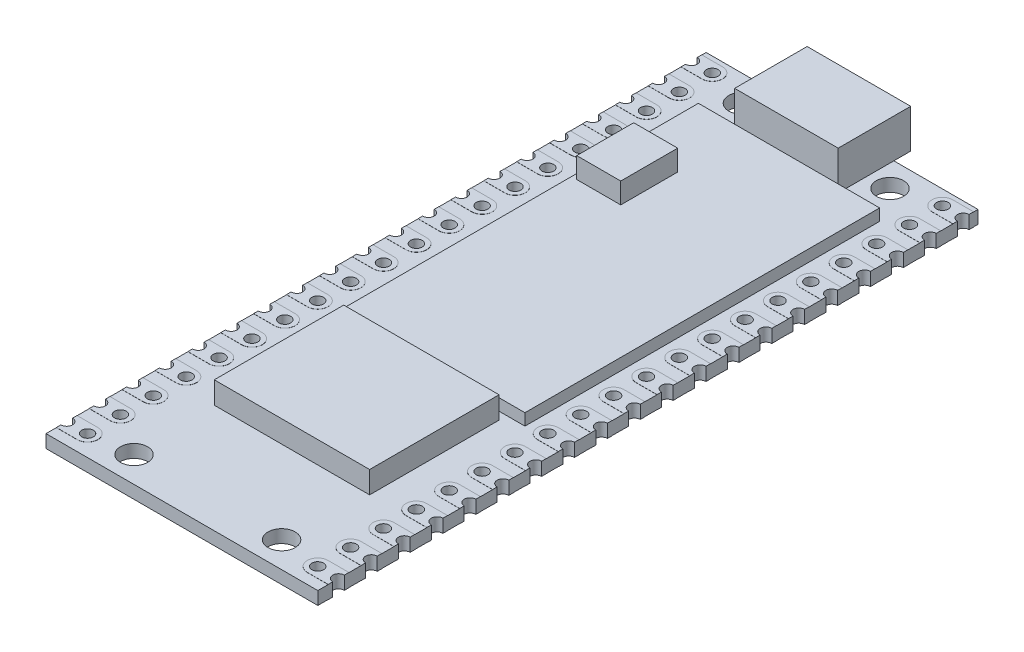
from build123d import *

# Parameters (mm, degrees)
SKETCH1_R                = 1.05
SKETCH1_R_2              = 0.45
BOSS_EXTRUDE1_DEPTH      = 1
SKETCH2_W                = 8
SKETCH2_H                = 5.6
BOSS_EXTRUDE2_DEPTH      = 3
SKETCH3_R                = 0.45
BOSS_EXTRUDE3_DEPTH      = 0.01
BOSS_EXTRUDE3_DEPTH_BACK = 1.01
SKETCH4_W                = 14
SKETCH4_H                = 27.4
BOSS_EXTRUDE4_DEPTH      = 0.9
SKETCH5_W                = 3.4
SKETCH5_H                = 4.4
BOSS_EXTRUDE5_DEPTH      = 2.5
SKETCH6_W                = 12
SKETCH6_H                = 10
BOSS_EXTRUDE6_DEPTH      = 1.7


with BuildPart() as part:
    # Sketch1 → Boss-Extrude1 (new body)
    with BuildSketch(Plane(origin=(0, 0, 0), x_dir=(1, 0, 0), z_dir=(0, 1, 0))):
        with BuildLine():
            Line((-10.5, 0), (10.5, 0))
            Line((10.5, 0), (10.5, -0.69))
            ThreePointArc((10.5, -0.69), (10.05, -1.14), (10.5, -1.59))
            Line((10.5, -1.59), (10.5, -3.23))
            ThreePointArc((10.5, -3.23), (10.05, -3.68), (10.5, -4.13))
            Line((10.5, -4.13), (10.5, -5.77))
            ThreePointArc((10.5, -5.77), (10.05, -6.22), (10.5, -6.67))
            Line((10.5, -6.67), (10.5, -8.31))
            ThreePointArc((10.5, -8.31), (10.05, -8.76), (10.5, -9.21))
            Line((10.5, -9.21), (10.5, -10.85))
            ThreePointArc((10.5, -10.85), (10.05, -11.3), (10.5, -11.75))
            Line((10.5, -11.75), (10.5, -13.39))
            ThreePointArc((10.5, -13.39), (10.05, -13.84), (10.5, -14.29))
            Line((10.5, -14.29), (10.5, -15.93))
            ThreePointArc((10.5, -15.93), (10.05, -16.38), (10.5, -16.83))
            Line((10.5, -16.83), (10.5, -18.47))
            ThreePointArc((10.5, -18.47), (10.05, -18.92), (10.5, -19.37))
            Line((10.5, -19.37), (10.5, -21.01))
            ThreePointArc((10.5, -21.01), (10.05, -21.46), (10.5, -21.91))
            Line((10.5, -21.91), (10.5, -23.55))
            ThreePointArc((10.5, -23.55), (10.05, -24), (10.5, -24.45))
            Line((10.5, -24.45), (10.5, -26.09))
            ThreePointArc((10.5, -26.09), (10.05, -26.54), (10.5, -26.99))
            Line((10.5, -26.99), (10.5, -28.63))
            ThreePointArc((10.5, -28.63), (10.05, -29.08), (10.5, -29.53))
            Line((10.5, -29.53), (10.5, -31.17))
            ThreePointArc((10.5, -31.17), (10.05, -31.62), (10.5, -32.07))
            Line((10.5, -32.07), (10.5, -33.71))
            ThreePointArc((10.5, -33.71), (10.05, -34.16), (10.5, -34.61))
            Line((10.5, -34.61), (10.5, -36.25))
            ThreePointArc((10.5, -36.25), (10.05, -36.7), (10.5, -37.15))
            Line((10.5, -37.15), (10.5, -38.79))
            ThreePointArc((10.5, -38.79), (10.05, -39.24), (10.5, -39.69))
            Line((10.5, -39.69), (10.5, -41.33))
            ThreePointArc((10.5, -41.33), (10.05, -41.78), (10.5, -42.23))
            Line((10.5, -42.23), (10.5, -43.87))
            ThreePointArc((10.5, -43.87), (10.05, -44.32), (10.5, -44.77))
            Line((10.5, -44.77), (10.5, -46.41))
            ThreePointArc((10.5, -46.41), (10.05, -46.86), (10.5, -47.31))
            Line((10.5, -47.31), (10.5, -48.95))
            ThreePointArc((10.5, -48.95), (10.05, -49.4), (10.5, -49.85))
            Line((10.5, -49.85), (10.5, -51))
            Line((10.5, -51), (-10.5, -51))
            Line((-10.5, -51), (-10.5, -49.85))
            ThreePointArc((-10.5, -49.85), (-10.05, -49.4), (-10.5, -48.95))
            Line((-10.5, -48.95), (-10.5, -47.31))
            ThreePointArc((-10.5, -47.31), (-10.05, -46.86), (-10.5, -46.41))
            Line((-10.5, -46.41), (-10.5, -44.77))
            ThreePointArc((-10.5, -44.77), (-10.05, -44.32), (-10.5, -43.87))
            Line((-10.5, -43.87), (-10.5, -42.23))
            ThreePointArc((-10.5, -42.23), (-10.05, -41.78), (-10.5, -41.33))
            Line((-10.5, -41.33), (-10.5, -39.69))
            ThreePointArc((-10.5, -39.69), (-10.05, -39.24), (-10.5, -38.79))
            Line((-10.5, -38.79), (-10.5, -37.15))
            ThreePointArc((-10.5, -37.15), (-10.05, -36.7), (-10.5, -36.25))
            Line((-10.5, -36.25), (-10.5, -34.61))
            ThreePointArc((-10.5, -34.61), (-10.05, -34.16), (-10.5, -33.71))
            Line((-10.5, -33.71), (-10.5, -32.07))
            ThreePointArc((-10.5, -32.07), (-10.05, -31.62), (-10.5, -31.17))
            Line((-10.5, -31.17), (-10.5, -29.53))
            ThreePointArc((-10.5, -29.53), (-10.05, -29.08), (-10.5, -28.63))
            Line((-10.5, -28.63), (-10.5, -26.99))
            ThreePointArc((-10.5, -26.99), (-10.05, -26.54), (-10.5, -26.09))
            Line((-10.5, -26.09), (-10.5, -24.45))
            ThreePointArc((-10.5, -24.45), (-10.05, -24), (-10.5, -23.55))
            Line((-10.5, -23.55), (-10.5, -21.91))
            ThreePointArc((-10.5, -21.91), (-10.05, -21.46), (-10.5, -21.01))
            Line((-10.5, -21.01), (-10.5, -19.37))
            ThreePointArc((-10.5, -19.37), (-10.05, -18.92), (-10.5, -18.47))
            Line((-10.5, -18.47), (-10.5, -16.83))
            ThreePointArc((-10.5, -16.83), (-10.05, -16.38), (-10.5, -15.93))
            Line((-10.5, -15.93), (-10.5, -14.29))
            ThreePointArc((-10.5, -14.29), (-10.05, -13.84), (-10.5, -13.39))
            Line((-10.5, -13.39), (-10.5, -11.75))
            ThreePointArc((-10.5, -11.75), (-10.05, -11.3), (-10.5, -10.85))
            Line((-10.5, -10.85), (-10.5, -9.21))
            ThreePointArc((-10.5, -9.21), (-10.05, -8.76), (-10.5, -8.31))
            Line((-10.5, -8.31), (-10.5, -6.67))
            ThreePointArc((-10.5, -6.67), (-10.05, -6.22), (-10.5, -5.77))
            Line((-10.5, -5.77), (-10.5, -4.13))
            ThreePointArc((-10.5, -4.13), (-10.05, -3.68), (-10.5, -3.23))
            Line((-10.5, -3.23), (-10.5, -1.59))
            ThreePointArc((-10.5, -1.59), (-10.05, -1.14), (-10.5, -0.69))
            Line((-10.5, -0.69), (-10.5, 0))
        make_face()
        with Locations(Location((-5.7, -2, 0), (0, 0, 270))):
            Circle(SKETCH1_R, mode=Mode.SUBTRACT)
        with Locations(Location((5.7, -2, 0), (0, 0, 90))):
            Circle(SKETCH1_R, mode=Mode.SUBTRACT)
        with Locations(Location((-8.89, -49.4, 0), (0, 0, 270))):
            Circle(SKETCH1_R_2, mode=Mode.SUBTRACT)
        with Locations(Location((5.7, -49, 0), (0, 0, 270))):
            Circle(SKETCH1_R, mode=Mode.SUBTRACT)
        with Locations(Location((-5.7, -49, 0), (0, 0, 90))):
            Circle(SKETCH1_R, mode=Mode.SUBTRACT)
        with Locations(Location((8.89, -49.4, 0), (0, 0, 90))):
            Circle(SKETCH1_R_2, mode=Mode.SUBTRACT)
        with Locations(Location((-8.89, -46.86, 0), (0, 0, 270))):
            Circle(SKETCH1_R_2, mode=Mode.SUBTRACT)
        with Locations(Location((8.89, -46.86, 0), (0, 0, 90))):
            Circle(SKETCH1_R_2, mode=Mode.SUBTRACT)
        with Locations(Location((-8.89, -44.32, 0), (0, 0, 270))):
            Circle(SKETCH1_R_2, mode=Mode.SUBTRACT)
        with Locations(Location((8.89, -44.32, 0), (0, 0, 90))):
            Circle(SKETCH1_R_2, mode=Mode.SUBTRACT)
        with Locations(Location((-8.89, -41.78, 0), (0, 0, 270))):
            Circle(SKETCH1_R_2, mode=Mode.SUBTRACT)
        with Locations(Location((8.89, -41.78, 0), (0, 0, 90))):
            Circle(SKETCH1_R_2, mode=Mode.SUBTRACT)
        with Locations(Location((-8.89, -39.24, 0), (0, 0, 270))):
            Circle(SKETCH1_R_2, mode=Mode.SUBTRACT)
        with Locations(Location((8.89, -39.24, 0), (0, 0, 90))):
            Circle(SKETCH1_R_2, mode=Mode.SUBTRACT)
        with Locations(Location((-8.89, -36.7, 0), (0, 0, 270))):
            Circle(SKETCH1_R_2, mode=Mode.SUBTRACT)
        with Locations(Location((8.89, -36.7, 0), (0, 0, 90))):
            Circle(SKETCH1_R_2, mode=Mode.SUBTRACT)
        with Locations(Location((-8.89, -34.16, 0), (0, 0, 270))):
            Circle(SKETCH1_R_2, mode=Mode.SUBTRACT)
        with Locations(Location((8.89, -34.16, 0), (0, 0, 90))):
            Circle(SKETCH1_R_2, mode=Mode.SUBTRACT)
        with Locations(Location((-8.89, -31.62, 0), (0, 0, 270))):
            Circle(SKETCH1_R_2, mode=Mode.SUBTRACT)
        with Locations(Location((8.89, -31.62, 0), (0, 0, 90))):
            Circle(SKETCH1_R_2, mode=Mode.SUBTRACT)
        with Locations(Location((-8.89, -29.08, 0), (0, 0, 270))):
            Circle(SKETCH1_R_2, mode=Mode.SUBTRACT)
        with Locations(Location((8.89, -29.08, 0), (0, 0, 90))):
            Circle(SKETCH1_R_2, mode=Mode.SUBTRACT)
        with Locations(Location((-8.89, -26.54, 0), (0, 0, 270))):
            Circle(SKETCH1_R_2, mode=Mode.SUBTRACT)
        with Locations(Location((8.89, -26.54, 0), (0, 0, 90))):
            Circle(SKETCH1_R_2, mode=Mode.SUBTRACT)
        with Locations(Location((-8.89, -24, 0), (0, 0, 270))):
            Circle(SKETCH1_R_2, mode=Mode.SUBTRACT)
        with Locations(Location((8.89, -24, 0), (0, 0, 90))):
            Circle(SKETCH1_R_2, mode=Mode.SUBTRACT)
        with Locations(Location((-8.89, -21.46, 0), (0, 0, 270))):
            Circle(SKETCH1_R_2, mode=Mode.SUBTRACT)
        with Locations(Location((8.89, -21.46, 0), (0, 0, 90))):
            Circle(SKETCH1_R_2, mode=Mode.SUBTRACT)
        with Locations(Location((-8.89, -18.92, 0), (0, 0, 270))):
            Circle(SKETCH1_R_2, mode=Mode.SUBTRACT)
        with Locations(Location((8.89, -18.92, 0), (0, 0, 90))):
            Circle(SKETCH1_R_2, mode=Mode.SUBTRACT)
        with Locations(Location((-8.89, -16.38, 0), (0, 0, 270))):
            Circle(SKETCH1_R_2, mode=Mode.SUBTRACT)
        with Locations(Location((8.89, -16.38, 0), (0, 0, 90))):
            Circle(SKETCH1_R_2, mode=Mode.SUBTRACT)
        with Locations(Location((-8.89, -13.84, 0), (0, 0, 270))):
            Circle(SKETCH1_R_2, mode=Mode.SUBTRACT)
        with Locations(Location((8.89, -13.84, 0), (0, 0, 90))):
            Circle(SKETCH1_R_2, mode=Mode.SUBTRACT)
        with Locations(Location((-8.89, -11.3, 0), (0, 0, 270))):
            Circle(SKETCH1_R_2, mode=Mode.SUBTRACT)
        with Locations(Location((8.89, -11.3, 0), (0, 0, 90))):
            Circle(SKETCH1_R_2, mode=Mode.SUBTRACT)
        with Locations(Location((-8.89, -8.76, 0), (0, 0, 270))):
            Circle(SKETCH1_R_2, mode=Mode.SUBTRACT)
        with Locations(Location((8.89, -8.76, 0), (0, 0, 90))):
            Circle(SKETCH1_R_2, mode=Mode.SUBTRACT)
        with Locations(Location((-8.89, -6.22, 0), (0, 0, 270))):
            Circle(SKETCH1_R_2, mode=Mode.SUBTRACT)
        with Locations(Location((8.89, -6.22, 0), (0, 0, 90))):
            Circle(SKETCH1_R_2, mode=Mode.SUBTRACT)
        with Locations(Location((-8.89, -3.68, 0), (0, 0, 270))):
            Circle(SKETCH1_R_2, mode=Mode.SUBTRACT)
        with Locations(Location((8.89, -3.68, 0), (0, 0, 90))):
            Circle(SKETCH1_R_2, mode=Mode.SUBTRACT)
        with Locations(Location((-8.89, -1.14, 0), (0, 0, 270))):
            Circle(SKETCH1_R_2, mode=Mode.SUBTRACT)
        with Locations(Location((8.89, -1.14, 0), (0, 0, 90))):
            Circle(SKETCH1_R_2, mode=Mode.SUBTRACT)
    extrude(amount=BOSS_EXTRUDE1_DEPTH)

    # Sketch2 → Boss-Extrude2 (add)
    with BuildSketch(Plane(origin=(0, 1, 0), x_dir=(1, 0, 0), z_dir=(0, 1, 0))):
        with Locations((0, -1.5)):
            Rectangle(SKETCH2_W, SKETCH2_H)
    extrude(amount=BOSS_EXTRUDE2_DEPTH)

    # Sketch3 → Boss-Extrude3 (add, two sides)
    with BuildSketch(Plane(origin=(0, 1, 0), x_dir=(1, 0, 0), z_dir=(0, 1, 0))) as boss_extrude3_sk:
        with BuildLine():
            Line((-8.89, -48.6), (-10.5, -48.6))
            Line((-10.5, -48.6), (-10.5, -48.95))
            ThreePointArc((-10.5, -48.95), (-10.05, -49.4), (-10.5, -49.85))
            Line((-10.5, -49.85), (-10.5, -50.2))
            Line((-10.5, -50.2), (-8.89, -50.2))
            ThreePointArc((-8.89, -50.2), (-8.09, -49.4), (-8.89, -48.6))
        make_face()
        with Locations(Location((-8.89, -49.4, 0), (0, 0, 270))):
            Circle(SKETCH3_R, mode=Mode.SUBTRACT)
        with BuildLine():
            Line((10.5, -50.2), (8.89, -50.2))
            ThreePointArc((8.89, -50.2), (8.09, -49.4), (8.89, -48.6))
            Line((8.89, -48.6), (10.5, -48.6))
            Line((10.5, -48.6), (10.5, -48.95))
            ThreePointArc((10.5, -48.95), (10.05, -49.4), (10.5, -49.85))
            Line((10.5, -49.85), (10.5, -50.2))
        make_face()
        with Locations(Location((8.89, -49.4, 0), (0, 0, 90))):
            Circle(SKETCH3_R, mode=Mode.SUBTRACT)
        with BuildLine():
            Line((-8.89, -46.06), (-10.5, -46.06))
            Line((-10.5, -46.06), (-10.5, -46.41))
            ThreePointArc((-10.5, -46.41), (-10.05, -46.86), (-10.5, -47.31))
            Line((-10.5, -47.31), (-10.5, -47.66))
            Line((-10.5, -47.66), (-8.89, -47.66))
            ThreePointArc((-8.89, -47.66), (-8.09, -46.86), (-8.89, -46.06))
        make_face()
        with Locations(Location((-8.89, -46.86, 0), (0, 0, 270))):
            Circle(SKETCH3_R, mode=Mode.SUBTRACT)
        with BuildLine():
            Line((10.5, -47.66), (8.89, -47.66))
            ThreePointArc((8.89, -47.66), (8.09, -46.86), (8.89, -46.06))
            Line((8.89, -46.06), (10.5, -46.06))
            Line((10.5, -46.06), (10.5, -46.41))
            ThreePointArc((10.5, -46.41), (10.05, -46.86), (10.5, -47.31))
            Line((10.5, -47.31), (10.5, -47.66))
        make_face()
        with Locations(Location((8.89, -46.86, 0), (0, 0, 90))):
            Circle(SKETCH3_R, mode=Mode.SUBTRACT)
        with BuildLine():
            Line((-8.89, -43.52), (-10.5, -43.52))
            Line((-10.5, -43.52), (-10.5, -43.87))
            ThreePointArc((-10.5, -43.87), (-10.05, -44.32), (-10.5, -44.77))
            Line((-10.5, -44.77), (-10.5, -45.12))
            Line((-10.5, -45.12), (-8.89, -45.12))
            ThreePointArc((-8.89, -45.12), (-8.09, -44.32), (-8.89, -43.52))
        make_face()
        with Locations(Location((-8.89, -44.32, 0), (0, 0, 270))):
            Circle(SKETCH3_R, mode=Mode.SUBTRACT)
        with BuildLine():
            Line((10.5, -45.12), (8.89, -45.12))
            ThreePointArc((8.89, -45.12), (8.09, -44.32), (8.89, -43.52))
            Line((8.89, -43.52), (10.5, -43.52))
            Line((10.5, -43.52), (10.5, -43.87))
            ThreePointArc((10.5, -43.87), (10.05, -44.32), (10.5, -44.77))
            Line((10.5, -44.77), (10.5, -45.12))
        make_face()
        with Locations(Location((8.89, -44.32, 0), (0, 0, 90))):
            Circle(SKETCH3_R, mode=Mode.SUBTRACT)
        with BuildLine():
            Line((-8.89, -40.98), (-10.5, -40.98))
            Line((-10.5, -40.98), (-10.5, -41.33))
            ThreePointArc((-10.5, -41.33), (-10.05, -41.78), (-10.5, -42.23))
            Line((-10.5, -42.23), (-10.5, -42.58))
            Line((-10.5, -42.58), (-8.89, -42.58))
            ThreePointArc((-8.89, -42.58), (-8.09, -41.78), (-8.89, -40.98))
        make_face()
        with Locations(Location((-8.89, -41.78, 0), (0, 0, 270))):
            Circle(SKETCH3_R, mode=Mode.SUBTRACT)
        with BuildLine():
            Line((10.5, -42.58), (8.89, -42.58))
            ThreePointArc((8.89, -42.58), (8.09, -41.78), (8.89, -40.98))
            Line((8.89, -40.98), (10.5, -40.98))
            Line((10.5, -40.98), (10.5, -41.33))
            ThreePointArc((10.5, -41.33), (10.05, -41.78), (10.5, -42.23))
            Line((10.5, -42.23), (10.5, -42.58))
        make_face()
        with Locations(Location((8.89, -41.78, 0), (0, 0, 90))):
            Circle(SKETCH3_R, mode=Mode.SUBTRACT)
        with BuildLine():
            Line((-8.89, -38.44), (-10.5, -38.44))
            Line((-10.5, -38.44), (-10.5, -38.79))
            ThreePointArc((-10.5, -38.79), (-10.05, -39.24), (-10.5, -39.69))
            Line((-10.5, -39.69), (-10.5, -40.04))
            Line((-10.5, -40.04), (-8.89, -40.04))
            ThreePointArc((-8.89, -40.04), (-8.09, -39.24), (-8.89, -38.44))
        make_face()
        with Locations(Location((-8.89, -39.24, 0), (0, 0, 270))):
            Circle(SKETCH3_R, mode=Mode.SUBTRACT)
        with BuildLine():
            Line((10.5, -40.04), (8.89, -40.04))
            ThreePointArc((8.89, -40.04), (8.09, -39.24), (8.89, -38.44))
            Line((8.89, -38.44), (10.5, -38.44))
            Line((10.5, -38.44), (10.5, -38.79))
            ThreePointArc((10.5, -38.79), (10.05, -39.24), (10.5, -39.69))
            Line((10.5, -39.69), (10.5, -40.04))
        make_face()
        with Locations(Location((8.89, -39.24, 0), (0, 0, 90))):
            Circle(SKETCH3_R, mode=Mode.SUBTRACT)
        with BuildLine():
            Line((-8.89, -35.9), (-10.5, -35.9))
            Line((-10.5, -35.9), (-10.5, -36.25))
            ThreePointArc((-10.5, -36.25), (-10.05, -36.7), (-10.5, -37.15))
            Line((-10.5, -37.15), (-10.5, -37.5))
            Line((-10.5, -37.5), (-8.89, -37.5))
            ThreePointArc((-8.89, -37.5), (-8.09, -36.7), (-8.89, -35.9))
        make_face()
        with Locations(Location((-8.89, -36.7, 0), (0, 0, 270))):
            Circle(SKETCH3_R, mode=Mode.SUBTRACT)
        with BuildLine():
            Line((10.5, -37.5), (8.89, -37.5))
            ThreePointArc((8.89, -37.5), (8.09, -36.7), (8.89, -35.9))
            Line((8.89, -35.9), (10.5, -35.9))
            Line((10.5, -35.9), (10.5, -36.25))
            ThreePointArc((10.5, -36.25), (10.05, -36.7), (10.5, -37.15))
            Line((10.5, -37.15), (10.5, -37.5))
        make_face()
        with Locations(Location((8.89, -36.7, 0), (0, 0, 90))):
            Circle(SKETCH3_R, mode=Mode.SUBTRACT)
        with BuildLine():
            Line((-8.89, -33.36), (-10.5, -33.36))
            Line((-10.5, -33.36), (-10.5, -33.71))
            ThreePointArc((-10.5, -33.71), (-10.05, -34.16), (-10.5, -34.61))
            Line((-10.5, -34.61), (-10.5, -34.96))
            Line((-10.5, -34.96), (-8.89, -34.96))
            ThreePointArc((-8.89, -34.96), (-8.09, -34.16), (-8.89, -33.36))
        make_face()
        with Locations(Location((-8.89, -34.16, 0), (0, 0, 270))):
            Circle(SKETCH3_R, mode=Mode.SUBTRACT)
        with BuildLine():
            Line((10.5, -34.96), (8.89, -34.96))
            ThreePointArc((8.89, -34.96), (8.09, -34.16), (8.89, -33.36))
            Line((8.89, -33.36), (10.5, -33.36))
            Line((10.5, -33.36), (10.5, -33.71))
            ThreePointArc((10.5, -33.71), (10.05, -34.16), (10.5, -34.61))
            Line((10.5, -34.61), (10.5, -34.96))
        make_face()
        with Locations(Location((8.89, -34.16, 0), (0, 0, 90))):
            Circle(SKETCH3_R, mode=Mode.SUBTRACT)
        with BuildLine():
            Line((-8.89, -30.82), (-10.5, -30.82))
            Line((-10.5, -30.82), (-10.5, -31.17))
            ThreePointArc((-10.5, -31.17), (-10.05, -31.62), (-10.5, -32.07))
            Line((-10.5, -32.07), (-10.5, -32.42))
            Line((-10.5, -32.42), (-8.89, -32.42))
            ThreePointArc((-8.89, -32.42), (-8.09, -31.62), (-8.89, -30.82))
        make_face()
        with Locations(Location((-8.89, -31.62, 0), (0, 0, 270))):
            Circle(SKETCH3_R, mode=Mode.SUBTRACT)
        with BuildLine():
            Line((10.5, -32.42), (8.89, -32.42))
            ThreePointArc((8.89, -32.42), (8.09, -31.62), (8.89, -30.82))
            Line((8.89, -30.82), (10.5, -30.82))
            Line((10.5, -30.82), (10.5, -31.17))
            ThreePointArc((10.5, -31.17), (10.05, -31.62), (10.5, -32.07))
            Line((10.5, -32.07), (10.5, -32.42))
        make_face()
        with Locations(Location((8.89, -31.62, 0), (0, 0, 90))):
            Circle(SKETCH3_R, mode=Mode.SUBTRACT)
        with BuildLine():
            Line((-8.89, -28.28), (-10.5, -28.28))
            Line((-10.5, -28.28), (-10.5, -28.63))
            ThreePointArc((-10.5, -28.63), (-10.05, -29.08), (-10.5, -29.53))
            Line((-10.5, -29.53), (-10.5, -29.88))
            Line((-10.5, -29.88), (-8.89, -29.88))
            ThreePointArc((-8.89, -29.88), (-8.09, -29.08), (-8.89, -28.28))
        make_face()
        with Locations(Location((-8.89, -29.08, 0), (0, 0, 270))):
            Circle(SKETCH3_R, mode=Mode.SUBTRACT)
        with BuildLine():
            Line((10.5, -29.88), (8.89, -29.88))
            ThreePointArc((8.89, -29.88), (8.09, -29.08), (8.89, -28.28))
            Line((8.89, -28.28), (10.5, -28.28))
            Line((10.5, -28.28), (10.5, -28.63))
            ThreePointArc((10.5, -28.63), (10.05, -29.08), (10.5, -29.53))
            Line((10.5, -29.53), (10.5, -29.88))
        make_face()
        with Locations(Location((8.89, -29.08, 0), (0, 0, 90))):
            Circle(SKETCH3_R, mode=Mode.SUBTRACT)
        with BuildLine():
            Line((-8.89, -25.74), (-10.5, -25.74))
            Line((-10.5, -25.74), (-10.5, -26.09))
            ThreePointArc((-10.5, -26.09), (-10.05, -26.54), (-10.5, -26.99))
            Line((-10.5, -26.99), (-10.5, -27.34))
            Line((-10.5, -27.34), (-8.89, -27.34))
            ThreePointArc((-8.89, -27.34), (-8.09, -26.54), (-8.89, -25.74))
        make_face()
        with Locations(Location((-8.89, -26.54, 0), (0, 0, 270))):
            Circle(SKETCH3_R, mode=Mode.SUBTRACT)
        with BuildLine():
            Line((10.5, -27.34), (8.89, -27.34))
            ThreePointArc((8.89, -27.34), (8.09, -26.54), (8.89, -25.74))
            Line((8.89, -25.74), (10.5, -25.74))
            Line((10.5, -25.74), (10.5, -26.09))
            ThreePointArc((10.5, -26.09), (10.05, -26.54), (10.5, -26.99))
            Line((10.5, -26.99), (10.5, -27.34))
        make_face()
        with Locations(Location((8.89, -26.54, 0), (0, 0, 90))):
            Circle(SKETCH3_R, mode=Mode.SUBTRACT)
        with BuildLine():
            Line((-8.89, -23.2), (-10.5, -23.2))
            Line((-10.5, -23.2), (-10.5, -23.55))
            ThreePointArc((-10.5, -23.55), (-10.05, -24), (-10.5, -24.45))
            Line((-10.5, -24.45), (-10.5, -24.8))
            Line((-10.5, -24.8), (-8.89, -24.8))
            ThreePointArc((-8.89, -24.8), (-8.09, -24), (-8.89, -23.2))
        make_face()
        with Locations(Location((-8.89, -24, 0), (0, 0, 270))):
            Circle(SKETCH3_R, mode=Mode.SUBTRACT)
        with BuildLine():
            Line((10.5, -24.8), (8.89, -24.8))
            ThreePointArc((8.89, -24.8), (8.09, -24), (8.89, -23.2))
            Line((8.89, -23.2), (10.5, -23.2))
            Line((10.5, -23.2), (10.5, -23.55))
            ThreePointArc((10.5, -23.55), (10.05, -24), (10.5, -24.45))
            Line((10.5, -24.45), (10.5, -24.8))
        make_face()
        with Locations(Location((8.89, -24, 0), (0, 0, 90))):
            Circle(SKETCH3_R, mode=Mode.SUBTRACT)
        with BuildLine():
            Line((-8.89, -20.66), (-10.5, -20.66))
            Line((-10.5, -20.66), (-10.5, -21.01))
            ThreePointArc((-10.5, -21.01), (-10.05, -21.46), (-10.5, -21.91))
            Line((-10.5, -21.91), (-10.5, -22.26))
            Line((-10.5, -22.26), (-8.89, -22.26))
            ThreePointArc((-8.89, -22.26), (-8.09, -21.46), (-8.89, -20.66))
        make_face()
        with Locations(Location((-8.89, -21.46, 0), (0, 0, 270))):
            Circle(SKETCH3_R, mode=Mode.SUBTRACT)
        with BuildLine():
            Line((10.5, -22.26), (8.89, -22.26))
            ThreePointArc((8.89, -22.26), (8.09, -21.46), (8.89, -20.66))
            Line((8.89, -20.66), (10.5, -20.66))
            Line((10.5, -20.66), (10.5, -21.01))
            ThreePointArc((10.5, -21.01), (10.05, -21.46), (10.5, -21.91))
            Line((10.5, -21.91), (10.5, -22.26))
        make_face()
        with Locations(Location((8.89, -21.46, 0), (0, 0, 90))):
            Circle(SKETCH3_R, mode=Mode.SUBTRACT)
        with BuildLine():
            Line((-8.89, -18.12), (-10.5, -18.12))
            Line((-10.5, -18.12), (-10.5, -18.47))
            ThreePointArc((-10.5, -18.47), (-10.05, -18.92), (-10.5, -19.37))
            Line((-10.5, -19.37), (-10.5, -19.72))
            Line((-10.5, -19.72), (-8.89, -19.72))
            ThreePointArc((-8.89, -19.72), (-8.09, -18.92), (-8.89, -18.12))
        make_face()
        with Locations(Location((-8.89, -18.92, 0), (0, 0, 270))):
            Circle(SKETCH3_R, mode=Mode.SUBTRACT)
        with BuildLine():
            Line((10.5, -19.72), (8.89, -19.72))
            ThreePointArc((8.89, -19.72), (8.09, -18.92), (8.89, -18.12))
            Line((8.89, -18.12), (10.5, -18.12))
            Line((10.5, -18.12), (10.5, -18.47))
            ThreePointArc((10.5, -18.47), (10.05, -18.92), (10.5, -19.37))
            Line((10.5, -19.37), (10.5, -19.72))
        make_face()
        with Locations(Location((8.89, -18.92, 0), (0, 0, 90))):
            Circle(SKETCH3_R, mode=Mode.SUBTRACT)
        with BuildLine():
            Line((-8.89, -15.58), (-10.5, -15.58))
            Line((-10.5, -15.58), (-10.5, -15.93))
            ThreePointArc((-10.5, -15.93), (-10.05, -16.38), (-10.5, -16.83))
            Line((-10.5, -16.83), (-10.5, -17.18))
            Line((-10.5, -17.18), (-8.89, -17.18))
            ThreePointArc((-8.89, -17.18), (-8.09, -16.38), (-8.89, -15.58))
        make_face()
        with Locations(Location((-8.89, -16.38, 0), (0, 0, 270))):
            Circle(SKETCH3_R, mode=Mode.SUBTRACT)
        with BuildLine():
            Line((10.5, -17.18), (8.89, -17.18))
            ThreePointArc((8.89, -17.18), (8.09, -16.38), (8.89, -15.58))
            Line((8.89, -15.58), (10.5, -15.58))
            Line((10.5, -15.58), (10.5, -15.93))
            ThreePointArc((10.5, -15.93), (10.05, -16.38), (10.5, -16.83))
            Line((10.5, -16.83), (10.5, -17.18))
        make_face()
        with Locations(Location((8.89, -16.38, 0), (0, 0, 90))):
            Circle(SKETCH3_R, mode=Mode.SUBTRACT)
        with BuildLine():
            Line((-8.89, -13.04), (-10.5, -13.04))
            Line((-10.5, -13.04), (-10.5, -13.39))
            ThreePointArc((-10.5, -13.39), (-10.05, -13.84), (-10.5, -14.29))
            Line((-10.5, -14.29), (-10.5, -14.64))
            Line((-10.5, -14.64), (-8.89, -14.64))
            ThreePointArc((-8.89, -14.64), (-8.09, -13.84), (-8.89, -13.04))
        make_face()
        with Locations(Location((-8.89, -13.84, 0), (0, 0, 270))):
            Circle(SKETCH3_R, mode=Mode.SUBTRACT)
        with BuildLine():
            Line((10.5, -14.64), (8.89, -14.64))
            ThreePointArc((8.89, -14.64), (8.09, -13.84), (8.89, -13.04))
            Line((8.89, -13.04), (10.5, -13.04))
            Line((10.5, -13.04), (10.5, -13.39))
            ThreePointArc((10.5, -13.39), (10.05, -13.84), (10.5, -14.29))
            Line((10.5, -14.29), (10.5, -14.64))
        make_face()
        with Locations(Location((8.89, -13.84, 0), (0, 0, 90))):
            Circle(SKETCH3_R, mode=Mode.SUBTRACT)
        with BuildLine():
            Line((-8.89, -10.5), (-10.5, -10.5))
            Line((-10.5, -10.5), (-10.5, -10.85))
            ThreePointArc((-10.5, -10.85), (-10.05, -11.3), (-10.5, -11.75))
            Line((-10.5, -11.75), (-10.5, -12.1))
            Line((-10.5, -12.1), (-8.89, -12.1))
            ThreePointArc((-8.89, -12.1), (-8.09, -11.3), (-8.89, -10.5))
        make_face()
        with Locations(Location((-8.89, -11.3, 0), (0, 0, 270))):
            Circle(SKETCH3_R, mode=Mode.SUBTRACT)
        with BuildLine():
            Line((10.5, -12.1), (8.89, -12.1))
            ThreePointArc((8.89, -12.1), (8.09, -11.3), (8.89, -10.5))
            Line((8.89, -10.5), (10.5, -10.5))
            Line((10.5, -10.5), (10.5, -10.85))
            ThreePointArc((10.5, -10.85), (10.05, -11.3), (10.5, -11.75))
            Line((10.5, -11.75), (10.5, -12.1))
        make_face()
        with Locations(Location((8.89, -11.3, 0), (0, 0, 90))):
            Circle(SKETCH3_R, mode=Mode.SUBTRACT)
        with BuildLine():
            Line((-8.89, -7.96), (-10.5, -7.96))
            Line((-10.5, -7.96), (-10.5, -8.31))
            ThreePointArc((-10.5, -8.31), (-10.05, -8.76), (-10.5, -9.21))
            Line((-10.5, -9.21), (-10.5, -9.56))
            Line((-10.5, -9.56), (-8.89, -9.56))
            ThreePointArc((-8.89, -9.56), (-8.09, -8.76), (-8.89, -7.96))
        make_face()
        with Locations(Location((-8.89, -8.76, 0), (0, 0, 270))):
            Circle(SKETCH3_R, mode=Mode.SUBTRACT)
        with BuildLine():
            Line((10.5, -9.56), (8.89, -9.56))
            ThreePointArc((8.89, -9.56), (8.09, -8.76), (8.89, -7.96))
            Line((8.89, -7.96), (10.5, -7.96))
            Line((10.5, -7.96), (10.5, -8.31))
            ThreePointArc((10.5, -8.31), (10.05, -8.76), (10.5, -9.21))
            Line((10.5, -9.21), (10.5, -9.56))
        make_face()
        with Locations(Location((8.89, -8.76, 0), (0, 0, 90))):
            Circle(SKETCH3_R, mode=Mode.SUBTRACT)
        with BuildLine():
            Line((-8.89, -5.42), (-10.5, -5.42))
            Line((-10.5, -5.42), (-10.5, -5.77))
            ThreePointArc((-10.5, -5.77), (-10.05, -6.22), (-10.5, -6.67))
            Line((-10.5, -6.67), (-10.5, -7.02))
            Line((-10.5, -7.02), (-8.89, -7.02))
            ThreePointArc((-8.89, -7.02), (-8.09, -6.22), (-8.89, -5.42))
        make_face()
        with Locations(Location((-8.89, -6.22, 0), (0, 0, 270))):
            Circle(SKETCH3_R, mode=Mode.SUBTRACT)
        with BuildLine():
            Line((10.5, -7.02), (8.89, -7.02))
            ThreePointArc((8.89, -7.02), (8.09, -6.22), (8.89, -5.42))
            Line((8.89, -5.42), (10.5, -5.42))
            Line((10.5, -5.42), (10.5, -5.77))
            ThreePointArc((10.5, -5.77), (10.05, -6.22), (10.5, -6.67))
            Line((10.5, -6.67), (10.5, -7.02))
        make_face()
        with Locations(Location((8.89, -6.22, 0), (0, 0, 90))):
            Circle(SKETCH3_R, mode=Mode.SUBTRACT)
        with BuildLine():
            Line((-8.89, -2.88), (-10.5, -2.88))
            Line((-10.5, -2.88), (-10.5, -3.23))
            ThreePointArc((-10.5, -3.23), (-10.05, -3.68), (-10.5, -4.13))
            Line((-10.5, -4.13), (-10.5, -4.48))
            Line((-10.5, -4.48), (-8.89, -4.48))
            ThreePointArc((-8.89, -4.48), (-8.09, -3.68), (-8.89, -2.88))
        make_face()
        with Locations(Location((-8.89, -3.68, 0), (0, 0, 270))):
            Circle(SKETCH3_R, mode=Mode.SUBTRACT)
        with BuildLine():
            Line((10.5, -4.48), (8.89, -4.48))
            ThreePointArc((8.89, -4.48), (8.09, -3.68), (8.89, -2.88))
            Line((8.89, -2.88), (10.5, -2.88))
            Line((10.5, -2.88), (10.5, -3.23))
            ThreePointArc((10.5, -3.23), (10.05, -3.68), (10.5, -4.13))
            Line((10.5, -4.13), (10.5, -4.48))
        make_face()
        with Locations(Location((8.89, -3.68, 0), (0, 0, 90))):
            Circle(SKETCH3_R, mode=Mode.SUBTRACT)
        with BuildLine():
            Line((-8.89, -0.34), (-10.5, -0.34))
            Line((-10.5, -0.34), (-10.5, -0.69))
            ThreePointArc((-10.5, -0.69), (-10.05, -1.14), (-10.5, -1.59))
            Line((-10.5, -1.59), (-10.5, -1.94))
            Line((-10.5, -1.94), (-8.89, -1.94))
            ThreePointArc((-8.89, -1.94), (-8.09, -1.14), (-8.89, -0.34))
        make_face()
        with Locations(Location((-8.89, -1.14, 0), (0, 0, 270))):
            Circle(SKETCH3_R, mode=Mode.SUBTRACT)
        with BuildLine():
            Line((10.5, -1.94), (8.89, -1.94))
            ThreePointArc((8.89, -1.94), (8.09, -1.14), (8.89, -0.34))
            Line((8.89, -0.34), (10.5, -0.34))
            Line((10.5, -0.34), (10.5, -0.69))
            ThreePointArc((10.5, -0.69), (10.05, -1.14), (10.5, -1.59))
            Line((10.5, -1.59), (10.5, -1.94))
        make_face()
        with Locations(Location((8.89, -1.14, 0), (0, 0, 90))):
            Circle(SKETCH3_R, mode=Mode.SUBTRACT)
    extrude(amount=BOSS_EXTRUDE3_DEPTH)
    extrude(boss_extrude3_sk.sketch, amount=-BOSS_EXTRUDE3_DEPTH_BACK)

    # Sketch4 → Boss-Extrude4 (add)
    with BuildSketch(Plane(origin=(0, 1, 0), x_dir=(1, 0, 0), z_dir=(0, 1, 0))):
        with Locations((0.5, -18.3)):
            Rectangle(SKETCH4_W, SKETCH4_H)
    extrude(amount=BOSS_EXTRUDE4_DEPTH)

    # Sketch5 → Boss-Extrude5 (add)
    with BuildSketch(Plane(origin=(0, 1, 0), x_dir=(1, 0, 0), z_dir=(0, 1, 0))):
        with Locations((-4.4, -12.2)):
            Rectangle(SKETCH5_W, SKETCH5_H)
    extrude(amount=BOSS_EXTRUDE5_DEPTH)

    # Sketch6 → Boss-Extrude6 (add)
    with BuildSketch(Plane(origin=(0, 1, 0), x_dir=(1, 0, 0), z_dir=(0, 1, 0))):
        with Locations((0.1, -37.6)):
            Rectangle(SKETCH6_W, SKETCH6_H)
    extrude(amount=BOSS_EXTRUDE6_DEPTH)


solid = part.part
